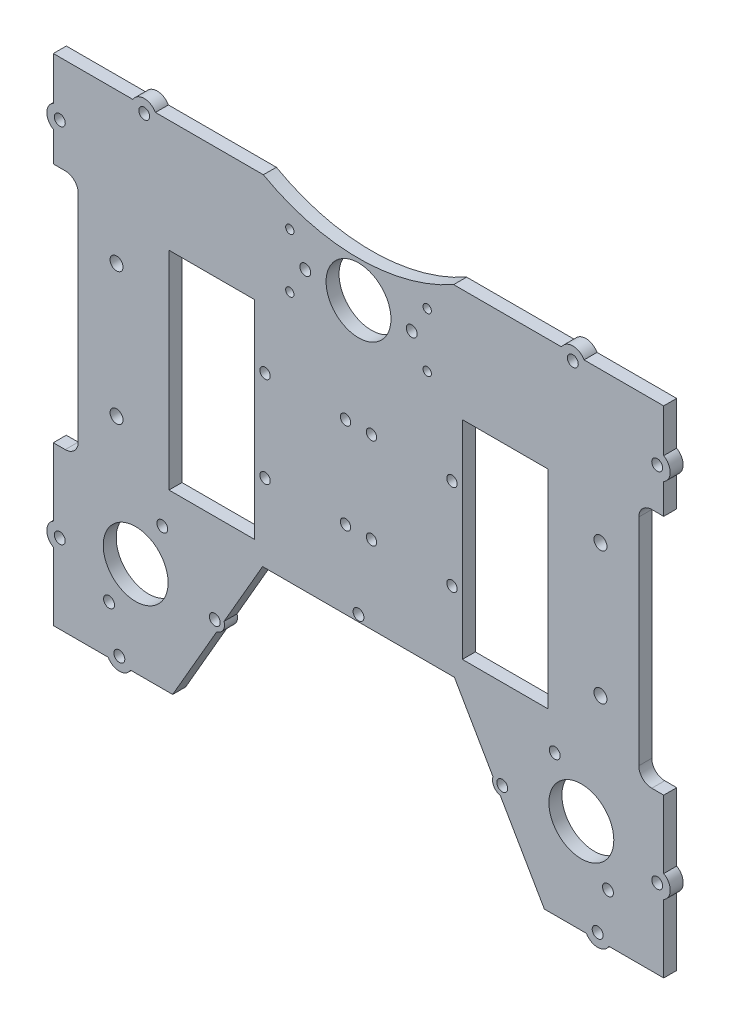
from build123d import *

# Parameters (mm, degrees)
BOSS_EXTRUDE1_DEPTH  = 5
CUT_EXTRUDE1_DEPTH   = 5
FILLET1_R            = 10
BOSS_EXTRUDE2_DEPTH  = 5
CUT_EXTRUDE3_DEPTH   = 10
SKETCH8_R            = 12.5
SKETCH8_R_2          = 2.1
CUT_EXTRUDE4_DEPTH   = 10
CUT_EXTRUDE5_DEPTH   = 10
FILLET4_R            = 10
CUT_EXTRUDE6_DEPTH   = 55
SKETCH12_R           = 12.5
SKETCH12_R_2         = 2.1
CUT_EXTRUDE7_DEPTH   = 10
SKETCH13_R           = 2.1
SKETCH13_R_2         = 2.097880452
CUT_EXTRUDE8_DEPTH   = 10
BOSS_EXTRUDE3_DEPTH  = 5
SKETCH15_R           = 1.6
CUT_EXTRUDE9_DEPTH   = 10
CUT_EXTRUDE10_DEPTH  = 10
FILLET5_R            = 15
SKETCH17_R           = 2.1
SKETCH17_R_2         = 12.5
BOSS_EXTRUDE4_DEPTH  = 5
CUT_EXTRUDE11_DEPTH  = 5
CUT_EXTRUDE13_DEPTH  = 5
BOSS_EXTRUDE7_DEPTH  = 5
SKETCH25_R           = 2.1
CUT_EXTRUDE15_DEPTH  = 5
BOSS_EXTRUDE8_DEPTH  = 5
SKETCH29_R           = 12.5
SKETCH29_R_2         = 2.1
CUT_EXTRUDE17_DEPTH  = 5
SKETCH31_R           = 2.1
SKETCH31_R_2         = 12.5
BOSS_EXTRUDE10_DEPTH = 5
SKETCH32_R           = 2.1
BOSS_EXTRUDE11_DEPTH = 5
SKETCH33_R           = 2.1
BOSS_EXTRUDE12_DEPTH = 5
CUT_EXTRUDE19_DEPTH  = 5
SKETCH37_W           = 236.187739262
SKETCH37_H           = 47.633249939
CUT_EXTRUDE21_DEPTH  = 10
CUT_EXTRUDE22_DEPTH  = 10
SKETCH41_R           = 12.5
SKETCH41_R_2         = 2.1
CUT_EXTRUDE23_DEPTH  = 10
SKETCH43_R           = 2
SKETCH43_W           = 33
SKETCH43_H           = 80
CUT_EXTRUDE24_DEPTH  = 10
SKETCH44_R           = 2.5
CUT_EXTRUDE25_DEPTH  = 10
SKETCH45_W           = 13.3
SKETCH45_H           = 92.98564038
CUT_EXTRUDE26_DEPTH  = 10
FILLET6_R            = 5
BOSS_EXTRUDE14_DEPTH = 5
SKETCH47_R           = 2.100093489
SKETCH47_R_2         = 2.1
SKETCH47_R_3         = 2.100705047
CUT_EXTRUDE27_DEPTH  = 5
SKETCH48_R           = 2.100208614
CUT_EXTRUDE28_DEPTH  = 5
CUT_EXTRUDE29_DEPTH  = 5
SKETCH50_R           = 2.100093489
SKETCH50_R_2         = 2.1
BOSS_EXTRUDE15_DEPTH = 5
BOSS_EXTRUDE16_DEPTH = 5
SKETCH53_R           = 2.1
CUT_EXTRUDE30_DEPTH  = 5


with BuildPart() as part:
    # Sketch2 → Boss-Extrude1 (new body)
    with BuildSketch(Plane.XY):
        with BuildLine():
            Line((118.854892482, -90.264830315), (131.354892482, -68.61419522))
            Line((131.354892482, -68.61419522), (131.354892482, -34.068551278))
            Line((131.354892482, -34.068551278), (131.354892482, -23.159839163))
            Line((131.354892482, -23.159839163), (131.354892482, 57.175005252))
            Line((131.354892482, 57.175005252), (131.354892482, 68.083717367))
            Line((131.354892482, 68.083717367), (131.354892482, 77.62936131))
            ThreePointArc((131.354892482, 77.62936131), (128.005527577, 90.12936131), (118.854892482, 99.279996404))
            Line((118.854892482, 99.279996404), (102.575593587, 108.678854004))
            Line((102.575593587, 108.678854004), (93.128371773, 114.133210061))
            Line((93.128371773, 114.133210061), (71.161779834, 126.81562783))
            ThreePointArc((71.161779834, 126.81562783), (70.530687733, 127.123084585), (69.862755205, 127.33912401))
            ThreePointArc((69.862755205, 127.33912401), (1.354892482, 71.71524119), (-67.152970241, 127.33912401))
            ThreePointArc((-67.152970241, 127.33912401), (-67.820902769, 127.123084585), (-68.45199487, 126.81562783))
            Line((-68.45199487, 126.81562783), (-90.418586809, 114.133210061))
            Line((-90.418586809, 114.133210061), (-99.865808623, 108.678854004))
            Line((-99.865808623, 108.678854004), (-116.145107518, 99.279996404))
            ThreePointArc((-116.145107518, 99.279996404), (-125.295742613, 90.12936131), (-128.645107518, 77.62936131))
            Line((-128.645107518, 77.62936131), (-128.645107518, 68.083717367))
            Line((-128.645107518, 68.083717367), (-128.645107518, 57.175005252))
            Line((-128.645107518, 57.175005252), (-128.645107518, -23.159839163))
            Line((-128.645107518, -23.159839163), (-128.645107518, -34.068551278))
            Line((-128.645107518, -34.068551278), (-128.645107518, -68.61419522))
            Line((-128.645107518, -68.61419522), (-116.145107518, -90.264830315))
            Line((-116.145107518, -90.264830315), (-48.645107518, -129.235973485))
            Line((-48.645107518, -129.235973485), (51.354892482, -129.235973485))
            Line((51.354892482, -129.235973485), (118.854892482, -90.264830315))
        make_face()
    extrude(amount=BOSS_EXTRUDE1_DEPTH)

    # Sketch4 → Cut-Extrude1 (cut)
    with BuildSketch(Plane.XY.offset(5)):
        with BuildLine():
            Line((76.324939807, 123.83467603), (71.161779834, 126.81562783))
            ThreePointArc((71.161779834, 126.81562783), (70.530687733, 127.123084585), (69.862755205, 127.33912401))
            ThreePointArc((69.862755205, 127.33912401), (1.354892482, 71.71524119), (-67.152970241, 127.33912401))
            ThreePointArc((-67.152970241, 127.33912401), (-67.820902769, 127.123084585), (-68.45199487, 126.81562783))
            Line((-68.45199487, 126.81562783), (-73.615154843, 123.83467603))
            ThreePointArc((-73.615154843, 123.83467603), (1.354892482, 46.71524119), (76.324939807, 123.83467603))
        make_face()
    extrude(amount=-CUT_EXTRUDE1_DEPTH, mode=Mode.SUBTRACT)

    # Fillet1
    fillet1_edges = [part.edges().sort_by_distance(p)[0] for p in [
        (76.324939807, 123.83467603, 2.5),
        (-73.615154843, 123.83467603, 2.5),
    ]]
    fillet(fillet1_edges, radius=FILLET1_R)

    # Sketch6 → Boss-Extrude2 (add)
    with BuildSketch(Plane.XY.offset(5)):
        Polygon((-128.645107518, -68.61419522), (-128.645107518, -169.952052331), (131.354892482, -169.952052331), (131.354892482, -68.61419522), (118.854892482, -90.264830315), (51.354892482, -129.235973485), (-48.645107518, -129.235973485), (-116.145107518, -90.264830315), align=None)
    extrude(amount=-BOSS_EXTRUDE2_DEPTH)

    # Sketch7 → Cut-Extrude3 (cut)
    with BuildSketch(Plane.XY.offset(5)):
        with BuildLine():
            Line((-116.215107518, -61.28475881), (-116.213411879, 18.71524119))
            Line((-116.213411879, 18.71524119), (-116.145107518, 99.279996404))
            ThreePointArc((-116.145107518, 99.279996404), (-125.295742613, 90.12936131), (-128.645107518, 77.62936131))
            Line((-128.645107518, 77.62936131), (-128.645107518, -169.952052331))
            Line((-128.645107518, -169.952052331), (-116.215107518, -169.952052331))
            Line((-116.215107518, -169.952052331), (-116.215107518, -61.28475881))
        make_face()
        with BuildLine():
            Line((118.924892482, -61.28475881), (118.924892482, -169.952052331))
            Line((118.924892482, -169.952052331), (131.354892482, -169.952052331))
            Line((131.354892482, -169.952052331), (131.354892482, 77.62936131))
            ThreePointArc((131.354892482, 77.62936131), (128.005527577, 90.12936131), (118.854892482, 99.279996404))
            Line((118.854892482, 99.279996404), (118.923196843, 18.71524119))
            Line((118.923196843, 18.71524119), (118.924892482, -61.28475881))
        make_face()
    extrude(amount=-CUT_EXTRUDE3_DEPTH, mode=Mode.SUBTRACT)

    # Sketch8 → Cut-Extrude4 (cut)
    with BuildSketch(Plane.XY.offset(5)):
        with Locations((1.354892482, -101.28475881)):
            Circle(SKETCH8_R)
        with Locations((21.854892482, -101.28475881)):
            Circle(SKETCH8_R_2)
        with Locations((-19.145107518, -101.28475881)):
            Circle(SKETCH8_R_2)
    extrude(amount=-CUT_EXTRUDE4_DEPTH, mode=Mode.SUBTRACT)

    # Sketch9 → Cut-Extrude5 (cut)
    with BuildSketch(Plane.XY.offset(5)):
        Polygon((118.924892482, -109.218146566), (94.040227372, -122.072981182), (-85.038192982, -122.072981182), (-116.215107518, -102.072981182), (-116.215107518, -169.952052331), (118.924892482, -169.952052331), align=None)
    extrude(amount=-CUT_EXTRUDE5_DEPTH, mode=Mode.SUBTRACT)

    # Fillet4
    fillet4_edges = [part.edges().sort_by_distance(p)[0] for p in [
        (-116.145107518, 99.279996404, 2.5),
        (118.854892482, 99.279996404, 2.5),
    ]]
    fillet(fillet4_edges, radius=FILLET4_R)

    # Sketch11 → Cut-Extrude6 (cut)
    with BuildSketch(Plane.XY.offset(5)):
        Polygon((115.38261843, -104.345351046), (87.747977946, -122.072981182), (94.040227372, -122.072981182), (118.924892482, -109.218146566), (118.924892482, -102.072981182), align=None)
    extrude(amount=-CUT_EXTRUDE6_DEPTH, mode=Mode.SUBTRACT)

    # Sketch12 → Cut-Extrude7 (cut)
    with BuildSketch(Plane.XY.offset(5)):
        with Locations((-87.399361691, 75.876360496)):
            Circle(SKETCH12_R)
        with Locations((-87.399361691, 96.376360496)):
            Circle(SKETCH12_R_2)
        with Locations((-87.399361691, 55.376360496)):
            Circle(SKETCH12_R_2)
        with Locations((90.109146655, 55.376360496)):
            Circle(SKETCH12_R_2)
        with Locations((90.109146655, 75.876360496)):
            Circle(SKETCH12_R)
        with Locations((90.109146655, 96.376360496)):
            Circle(SKETCH12_R_2)
    extrude(amount=-CUT_EXTRUDE7_DEPTH, mode=Mode.SUBTRACT)

    # Sketch13 → Cut-Extrude8 (cut)
    with BuildSketch(Plane.XY.offset(5)):
        with Locations((-97.505640106, -111.104922173)):
            Circle(SKETCH13_R)
        with Locations((-40.491777132, -119.572981182)):
            Circle(SKETCH13_R)
        with Locations((-113.715107518, -81.678869996)):
            Circle(SKETCH13_R)
        with Locations((-113.681704746, 56.11369386)):
            Circle(SKETCH13_R_2)
        with Locations((116.39148971, 56.11369386)):
            Circle(SKETCH13_R_2)
        with Locations((116.424892482, -81.678869996)):
            Circle(SKETCH13_R)
        with Locations((43.201562096, -119.572981182)):
            Circle(SKETCH13_R)
        with Locations((100.21542507, -111.104922173)):
            Circle(SKETCH13_R)
    extrude(amount=-CUT_EXTRUDE8_DEPTH, mode=Mode.SUBTRACT)

    # Sketch14 → Boss-Extrude3 (add)
    with BuildSketch(Plane.XY.offset(5)):
        with BuildLine():
            Line((-95.210855805, -115.547214938), (-102.500170642, -110.87111729))
            ThreePointArc((-102.500170642, -110.87111729), (-100.205386341, -115.313410056), (-95.210855805, -115.547214938))
        make_face()
        with BuildLine():
            Line((-116.215107518, -77.348742977), (-116.215107518, -86.008997015))
            ThreePointArc((-116.215107518, -86.008997015), (-118.715107518, -81.678869996), (-116.215107518, -77.348742977))
        make_face()
        with BuildLine():
            Line((-116.185374114, 51.785687426), (-116.178031784, 60.445939388))
            ThreePointArc((-116.178031784, 60.445939388), (-118.681702949, 56.117932955), (-116.185374114, 51.785687426))
        make_face()
        with BuildLine():
            Line((-36.161650113, -122.072981182), (-44.821904151, -122.072981182))
            ThreePointArc((-44.821904151, -122.072981182), (-40.491777132, -124.572981182), (-36.161650113, -122.072981182))
        make_face()
        with BuildLine():
            Line((38.871435077, -122.072981182), (47.531689115, -122.072981182))
            ThreePointArc((47.531689115, -122.072981182), (43.201562096, -124.572981182), (38.871435077, -122.072981182))
        make_face()
        with BuildLine():
            Line((118.895159078, 51.785687426), (118.887816748, 60.445939388))
            ThreePointArc((118.887816748, 60.445939388), (121.391487913, 56.117932955), (118.895159078, 51.785687426))
        make_face()
        with BuildLine():
            Line((118.924892482, -77.348742977), (118.924892482, -86.008997015))
            ThreePointArc((118.924892482, -86.008997015), (121.424892482, -81.678869996), (118.924892482, -77.348742977))
        make_face()
        with BuildLine():
            Line((97.920640769, -115.547214938), (105.209955606, -110.87111729))
            ThreePointArc((105.209955606, -110.87111729), (102.915171306, -115.313410056), (97.920640769, -115.547214938))
        make_face()
    extrude(amount=-BOSS_EXTRUDE3_DEPTH)

    # Sketch15 → Cut-Extrude9 (cut)
    with BuildSketch(Plane.XY.offset(5)):
        with Locations((-25.109573612, 25.679707284)):
            Circle(SKETCH15_R)
        with Locations((-25.109573612, 4.750775096)):
            Circle(SKETCH15_R)
        with Locations((27.819358576, 25.679707284)):
            Circle(SKETCH15_R)
        with Locations((27.819358576, 4.750775096)):
            Circle(SKETCH15_R)
    extrude(amount=-CUT_EXTRUDE9_DEPTH, mode=Mode.SUBTRACT)

    # Sketch16 → Cut-Extrude10 (cut)
    with BuildSketch(Plane.XY.offset(5)):
        with BuildLine():
            ThreePointArc((-72.545920023, 108.921887014), (1.354892482, 46.71524119), (75.255704987, 108.921887014))
            ThreePointArc((75.255704987, 108.921887014), (75.555506148, 110.170417386), (76.012819022, 111.370239773))
            ThreePointArc((76.012819022, 111.370239773), (1.354892482, 29.21524119), (-73.303034058, 111.370239773))
            ThreePointArc((-73.303034058, 111.370239773), (-72.845721184, 110.170417386), (-72.545920023, 108.921887014))
        make_face()
    extrude(amount=-CUT_EXTRUDE10_DEPTH, mode=Mode.SUBTRACT)

    # Fillet5
    fillet5_edges = [part.edges().sort_by_distance(p)[0] for p in [
        (76.012819022, 111.370239773, 2.5),
        (-73.303034058, 111.370239773, 2.5),
    ]]
    fillet(fillet5_edges, radius=FILLET5_R)

    # Sketch17 → Boss-Extrude4 (add)
    with BuildSketch(Plane.XY.offset(5)):
        with Locations((90.109146655, 55.376360496)):
            Circle(SKETCH17_R)
        with Locations((90.109146655, 96.376360496)):
            Circle(SKETCH17_R)
        with Locations((90.109146655, 75.876360496)):
            Circle(SKETCH17_R_2)
        with Locations((-87.399361691, 55.376360496)):
            Circle(SKETCH17_R)
        with Locations((-87.399361691, 96.376360496)):
            Circle(SKETCH17_R)
        with Locations((-87.399361691, 75.876360496)):
            Circle(SKETCH17_R_2)
    extrude(amount=-BOSS_EXTRUDE4_DEPTH)

    # Sketch18 → Cut-Extrude11 (cut)
    with BuildSketch(Plane.XY.offset(5)):
        with BuildLine():
            Line((-116.179388511, 58.845685421), (-71.106807034, 84.868352469))
            ThreePointArc((-71.106807034, 84.868352469), (-72.623753721, 91.879929846), (-73.463866886, 99.004363469))
            ThreePointArc((-73.463866886, 99.004363469), (-81.383699272, 111.205420092), (-95.92761876, 110.952568981))
            Line((-95.92761876, 110.952568981), (-111.150001207, 102.163922378))
            ThreePointArc((-111.150001207, 102.163922378), (-114.808134919, 98.507339055), (-116.149997613, 93.51214653))
            Line((-116.149997613, 93.51214653), (-116.178031784, 60.445939388))
            Line((-116.178031784, 60.445939388), (-116.179388511, 58.845685421))
        make_face()
        with BuildLine():
            Line((118.887816748, 60.445939388), (118.889173475, 58.845685421))
            Line((118.889173475, 58.845685421), (73.816591999, 84.868352469))
            ThreePointArc((73.816591999, 84.868352469), (75.333538685, 91.879929846), (76.17365185, 99.004363469))
            ThreePointArc((76.17365185, 99.004363469), (84.093484236, 111.205420092), (98.637403724, 110.952568981))
            Line((98.637403724, 110.952568981), (113.859786171, 102.163922378))
            ThreePointArc((113.859786171, 102.163922378), (117.517919883, 98.507339055), (118.859782577, 93.51214653))
            Line((118.859782577, 93.51214653), (118.887816748, 60.445939388))
        make_face()
    extrude(amount=-CUT_EXTRUDE11_DEPTH, mode=Mode.SUBTRACT)

    # Sketch20 → Cut-Extrude13 (cut)
    with BuildSketch(Plane.XY.offset(5)):
        with BuildLine():
            Line((-116.185374114, 51.785687426), (-116.179388511, 58.845685421))
            Line((-116.179388511, 58.845685421), (-116.178031784, 60.445939388))
            ThreePointArc((-116.178031784, 60.445939388), (-118.681702949, 56.117932955), (-116.185374114, 51.785687426))
        make_face()
        with BuildLine():
            Line((118.889173475, 58.845685421), (118.887816748, 60.445939388))
            ThreePointArc((118.887816748, 60.445939388), (121.391487913, 56.117932955), (118.895159078, 51.785687426))
            Line((118.895159078, 51.785687426), (118.889173475, 58.845685421))
        make_face()
    extrude(amount=-CUT_EXTRUDE13_DEPTH, mode=Mode.SUBTRACT)

    # Sketch24 → Boss-Extrude7 (add)
    with BuildSketch(Plane.XY.offset(5)):
        with BuildLine():
            Line((118.909854527, 34.452456871), (118.902512197, 43.112708833))
            ThreePointArc((118.902512197, 43.112708833), (121.406183362, 38.7847024), (118.909854527, 34.452456871))
        make_face()
        with BuildLine():
            Line((-116.200069563, 34.452456871), (-116.192727233, 43.112708833))
            ThreePointArc((-116.192727233, 43.112708833), (-118.696398398, 38.7847024), (-116.200069563, 34.452456871))
        make_face()
    extrude(amount=-BOSS_EXTRUDE7_DEPTH)

    # Sketch25 → Cut-Extrude15 (cut)
    with BuildSketch(Plane.XY.offset(5)):
        with Locations((-113.696400195, 38.780463305)):
            Circle(SKETCH25_R)
        with Locations((116.406185159, 38.780463305)):
            Circle(SKETCH25_R)
    extrude(amount=-CUT_EXTRUDE15_DEPTH, mode=Mode.SUBTRACT)

    # Sketch26 → Boss-Extrude8 (add)
    with BuildSketch(Plane.XY.offset(5)):
        with BuildLine():
            Line((-56.145107518, -152.072981182), (-26.145107518, -122.072981182))
            Line((-26.145107518, -122.072981182), (-36.161650113, -122.072981182))
            ThreePointArc((-36.161650113, -122.072981182), (-40.491777132, -124.572981182), (-44.821904151, -122.072981182))
            Line((-44.821904151, -122.072981182), (-85.038192982, -122.072981182))
            Line((-85.038192982, -122.072981182), (-95.210855805, -115.547214938))
            ThreePointArc((-95.210855805, -115.547214938), (-100.205386341, -115.313410056), (-102.500170642, -110.87111729))
            Line((-102.500170642, -110.87111729), (-116.215107518, -102.072981182))
            Line((-116.215107518, -102.072981182), (-116.215107518, -152.072981182))
            Line((-116.215107518, -152.072981182), (-105.295228274, -152.072981182))
            Line((-105.295228274, -152.072981182), (-56.145107518, -152.072981182))
        make_face()
        with BuildLine():
            ThreePointArc((97.920640769, -115.547214938), (102.915171306, -115.313410056), (105.209955606, -110.87111729))
            Line((105.209955606, -110.87111729), (118.924892482, -102.072981182))
            Line((118.924892482, -102.072981182), (118.924892482, -152.072981182))
            Line((118.924892482, -152.072981182), (108.005013238, -152.072981182))
            Line((108.005013238, -152.072981182), (58.854892482, -152.072981182))
            Line((58.854892482, -152.072981182), (28.854892482, -122.072981182))
            Line((28.854892482, -122.072981182), (38.871435077, -122.072981182))
            ThreePointArc((38.871435077, -122.072981182), (43.201562096, -124.572981182), (47.531689115, -122.072981182))
            Line((47.531689115, -122.072981182), (87.747977946, -122.072981182))
            Line((87.747977946, -122.072981182), (97.920640769, -115.547214938))
        make_face()
    extrude(amount=-BOSS_EXTRUDE8_DEPTH)

    # Sketch29 → Cut-Extrude17 (cut)
    with BuildSketch(Plane.XY.offset(5)):
        with Locations((1.354892482, 15.21524119)):
            Circle(SKETCH29_R)
        with Locations((21.854892482, 15.21524119)):
            Circle(SKETCH29_R_2)
        with Locations((-19.145107518, 15.21524119)):
            Circle(SKETCH29_R_2)
    extrude(amount=-CUT_EXTRUDE17_DEPTH, mode=Mode.SUBTRACT)

    # Sketch31 → Boss-Extrude10 (add)
    with BuildSketch(Plane.XY.offset(5)):
        with Locations((-19.145107518, -101.28475881)):
            Circle(SKETCH31_R)
        with Locations((21.854892482, -101.28475881)):
            Circle(SKETCH31_R)
        with Locations((1.354892482, -101.28475881)):
            Circle(SKETCH31_R_2)
    extrude(amount=-BOSS_EXTRUDE10_DEPTH)

    # Sketch32 → Boss-Extrude11 (add)
    with BuildSketch(Plane.XY.offset(5)):
        with Locations((100.21542507, -111.104922173)):
            Circle(SKETCH32_R)
        with Locations((43.201562096, -119.572981182)):
            Circle(SKETCH32_R)
        with Locations((-97.505640106, -111.104922173)):
            Circle(SKETCH32_R)
        with Locations((-40.491777132, -119.572981182)):
            Circle(SKETCH32_R)
    extrude(amount=-BOSS_EXTRUDE11_DEPTH)

    # Sketch33 → Boss-Extrude12 (add)
    with BuildSketch(Plane.XY.offset(5)):
        with Locations((116.406185159, 38.780463305)):
            Circle(SKETCH33_R)
        with Locations((116.424892482, -81.678869996)):
            Circle(SKETCH33_R)
        with Locations((-113.715107518, -81.678869996)):
            Circle(SKETCH33_R)
        with Locations((-113.696400195, 38.780463305)):
            Circle(SKETCH33_R)
    extrude(amount=-BOSS_EXTRUDE12_DEPTH)

    # Sketch34 → Cut-Extrude19 (cut)
    with BuildSketch(Plane.XY.offset(5)):
        with BuildLine():
            Line((-116.192727233, 43.112708833), (-116.200069563, 34.452456871))
            ThreePointArc((-116.200069563, 34.452456871), (-118.696398398, 38.7847024), (-116.192727233, 43.112708833))
        make_face()
        with BuildLine():
            Line((-116.215107518, -86.008997015), (-116.215107518, -77.348742977))
            ThreePointArc((-116.215107518, -77.348742977), (-118.715107518, -81.678869996), (-116.215107518, -86.008997015))
        make_face()
        with BuildLine():
            Line((118.902512197, 43.112708833), (118.909854527, 34.452456871))
            ThreePointArc((118.909854527, 34.452456871), (121.406183362, 38.7847024), (118.902512197, 43.112708833))
        make_face()
        with BuildLine():
            Line((118.924892482, -77.348742977), (118.924892482, -86.008997015))
            ThreePointArc((118.924892482, -86.008997015), (121.424892482, -81.678869996), (118.924892482, -77.348742977))
        make_face()
    extrude(amount=-CUT_EXTRUDE19_DEPTH, mode=Mode.SUBTRACT)

    # Sketch37 → Cut-Extrude21 (cut)
    with BuildSketch(Plane.XY.offset(5)):
        with Locations((1.897469436, 62.597088275)):
            Rectangle(SKETCH37_W, SKETCH37_H)
    extrude(amount=-CUT_EXTRUDE21_DEPTH, mode=Mode.SUBTRACT)

    # Sketch38 → Cut-Extrude22 (cut)
    with BuildSketch(Plane.XY.offset(5)):
        Polygon((-35.595524746, -92.072981182), (33.754047831, -92.072981182), (38.30530971, -92.072981182), (72.946325862, -152.072981182), (58.854892482, -152.072981182), (28.854892482, -122.072981182), (-26.145107518, -122.072981182), (-56.145107518, -152.072981182), (-70.236540897, -152.072981182), align=None)
    extrude(amount=-CUT_EXTRUDE22_DEPTH, mode=Mode.SUBTRACT)

    # Sketch41 → Cut-Extrude23 (cut)
    with BuildSketch(Plane.XY.offset(5)):
        with Locations((87.197008489, -115.686016305)):
            Circle(SKETCH41_R)
        with Locations((97.447008489, -133.439537083)):
            Circle(SKETCH41_R_2)
        with Locations((76.947008489, -97.932495528)):
            Circle(SKETCH41_R_2)
        with Locations((-74.237223525, -97.932495528)):
            Circle(SKETCH41_R_2)
        with Locations((-94.737223525, -133.439537083)):
            Circle(SKETCH41_R_2)
        with Locations((-84.487223525, -115.686016305)):
            Circle(SKETCH41_R)
    extrude(amount=-CUT_EXTRUDE23_DEPTH, mode=Mode.SUBTRACT)

    # Sketch43 → Cut-Extrude24 (cut)
    with BuildSketch(Plane.XY.offset(5)):
        with Locations((-34.645107518, -27.072981182)):
            Circle(SKETCH43_R)
        with Locations((-3.645107518, -27.072981182)):
            Circle(SKETCH43_R)
        with Locations((6.354892482, -27.072981182)):
            Circle(SKETCH43_R)
        with Locations((37.354892482, -27.072981182)):
            Circle(SKETCH43_R)
        with Locations((-34.645107518, -62.072981182)):
            Circle(SKETCH43_R)
        with Locations((-3.645107518, -62.072981182)):
            Circle(SKETCH43_R)
        with Locations((6.354892482, -62.072981182)):
            Circle(SKETCH43_R)
        with Locations((37.354892482, -62.072981182)):
            Circle(SKETCH43_R)
        with Locations((-55.145107518, -44.572981182)):
            Rectangle(SKETCH43_W, SKETCH43_H)
        with Locations((57.854892482, -44.572981182)):
            Rectangle(SKETCH43_W, SKETCH43_H)
    extrude(amount=-CUT_EXTRUDE24_DEPTH, mode=Mode.SUBTRACT)

    # Sketch44 → Cut-Extrude25 (cut)
    with BuildSketch(Plane.XY.offset(5)):
        with Locations((-91.845107518, -19.072981182)):
            Circle(SKETCH44_R)
        with Locations((-91.845107518, -70.072981182)):
            Circle(SKETCH44_R)
        with Locations((94.554892482, -19.072981182)):
            Circle(SKETCH44_R)
        with Locations((94.554892482, -70.072981182)):
            Circle(SKETCH44_R)
    extrude(amount=-CUT_EXTRUDE25_DEPTH, mode=Mode.SUBTRACT)

    # Sketch45 → Cut-Extrude26 (cut)
    with BuildSketch(Plane.XY.offset(5)):
        with Locations((-113.265107518, -44.572981182)):
            Rectangle(SKETCH45_W, SKETCH45_H)
        with Locations((115.974892482, -44.572981182)):
            Rectangle(SKETCH45_W, SKETCH45_H)
    extrude(amount=-CUT_EXTRUDE26_DEPTH, mode=Mode.SUBTRACT)

    # Fillet6
    fillet6_edges = [part.edges().sort_by_distance(p)[0] for p in [
        (-106.615107518, 1.919839008, 2.5),
        (-106.615107518, -91.065801372, 2.5),
        (109.324892482, -91.065801372, 2.5),
        (109.324892482, 1.919839008, 2.5),
    ]]
    fillet(fillet6_edges, radius=FILLET6_R)

    # Sketch46 → Boss-Extrude14 (add)
    with BuildSketch(Plane.XY.offset(5)):
        with BuildLine():
            Line((-116.213411879, 18.71524119), (-116.210476707, 22.177266344))
            ThreePointArc((-116.210476707, 22.177266344), (-118.704727915, 17.852223146), (-116.21352188, 13.525425225))
            Line((-116.21352188, 13.525425225), (-116.213411879, 18.71524119))
        make_face()
        with BuildLine():
            Line((-80.076246748, 38.780463305), (-71.41599271, 38.780463305))
            ThreePointArc((-71.41599271, 38.780463305), (-75.746119729, 41.280463305), (-80.076246748, 38.780463305))
        make_face()
        with BuildLine():
            Line((-116.215107518, -117.237854163), (-116.215107518, -125.898108201))
            ThreePointArc((-116.215107518, -125.898108201), (-118.715107518, -121.567981182), (-116.215107518, -117.237854163))
        make_face()
        with BuildLine():
            Line((55.951852196, -122.637689346), (53.156767224, -117.796460163))
            ThreePointArc((53.156767224, -117.796460163), (53.471777955, -120.842074754), (55.951852196, -122.637689346))
        make_face()
        with BuildLine():
            Line((97.810019501, -152.072981182), (89.149765463, -152.072981182))
            ThreePointArc((89.149765463, -152.072981182), (93.479892482, -154.572981182), (97.810019501, -152.072981182))
        make_face()
        with BuildLine():
            Line((118.924892482, -117.238559211), (118.924892482, -125.898813249))
            ThreePointArc((118.924892482, -125.898813249), (121.424892482, -121.56868623), (118.924892482, -117.238559211))
        make_face()
        with BuildLine():
            Line((118.923196843, 18.71524119), (118.923306737, 13.530484573))
            ThreePointArc((118.923306737, 13.530484573), (121.405810895, 17.852222664), (118.920265956, 22.172212639))
            Line((118.920265956, 22.172212639), (118.923196843, 18.71524119))
        make_face()
        with BuildLine():
            Line((74.125684186, 38.780463305), (82.785938223, 38.780463305))
            ThreePointArc((82.785938223, 38.780463305), (78.455811205, 41.280463305), (74.125684186, 38.780463305))
        make_face()
        with BuildLine():
            ThreePointArc((-95.100234537, -152.072981182), (-90.770107518, -154.572981182), (-86.439980499, -152.072981182))
            Line((-86.439980499, -152.072981182), (-95.100234537, -152.072981182))
        make_face()
        with BuildLine():
            ThreePointArc((-53.242067232, -122.637689346), (-50.761992991, -120.842074754), (-50.44698226, -117.796460163))
            Line((-50.44698226, -117.796460163), (-53.242067232, -122.637689346))
        make_face()
    extrude(amount=-BOSS_EXTRUDE14_DEPTH)

    # Sketch47 → Cut-Extrude27 (cut)
    with BuildSketch(Plane.XY.offset(5)):
        with Locations((-75.746119729, 36.280463305)):
            Circle(SKETCH47_R)
        with Locations((-113.715107518, -121.567981182)):
            Circle(SKETCH47_R_2)
        with Locations((-90.770107518, -149.572981182)):
            Circle(SKETCH47_R_2)
        with Locations((-54.009588256, -118.967074754)):
            Circle(SKETCH47_R_2)
        with Locations((56.71937322, -118.967074754)):
            Circle(SKETCH47_R_2)
        with Locations((93.479892482, -149.572981182)):
            Circle(SKETCH47_R_2)
        with Locations((116.424892482, -121.56868623)):
            Circle(SKETCH47_R_3)
        with Locations((116.405811205, 17.850463305)):
            Circle(SKETCH47_R_2)
        with Locations((78.455811205, 36.280463305)):
            Circle(SKETCH47_R_2)
        with Locations((-113.704728224, 17.850463305)):
            Circle(SKETCH47_R_2)
    extrude(amount=-CUT_EXTRUDE27_DEPTH, mode=Mode.SUBTRACT)

    # Sketch48 → Cut-Extrude28 (cut)
    with BuildSketch(Plane.XY.offset(5)):
        with Locations((1.355101096, -89.572981182)):
            Circle(SKETCH48_R)
    extrude(amount=-CUT_EXTRUDE28_DEPTH, mode=Mode.SUBTRACT)

    # Sketch49 → Cut-Extrude29 (cut)
    with BuildSketch(Plane.XY.offset(5)):
        with BuildLine():
            Line((-80.076246748, 38.780463305), (-71.41599271, 38.780463305))
            ThreePointArc((-71.41599271, 38.780463305), (-75.746119729, 41.280463305), (-80.076246748, 38.780463305))
        make_face()
        with BuildLine():
            Line((74.125684186, 38.780463305), (82.785938223, 38.780463305))
            ThreePointArc((82.785938223, 38.780463305), (78.455811205, 41.280463305), (74.125684186, 38.780463305))
        make_face()
    extrude(amount=-CUT_EXTRUDE29_DEPTH, mode=Mode.SUBTRACT)

    # Sketch50 → Boss-Extrude15 (add)
    with BuildSketch(Plane.XY.offset(5)):
        with Locations((-75.746119729, 36.280463305)):
            Circle(SKETCH50_R)
        with Locations((78.455811205, 36.280463305)):
            Circle(SKETCH50_R_2)
    extrude(amount=-BOSS_EXTRUDE15_DEPTH)

    # Sketch52 → Boss-Extrude16 (add)
    with BuildSketch(Plane.XY.offset(5)):
        with BuildLine():
            Line((79.57605814, 38.780463305), (88.236312178, 38.780463305))
            ThreePointArc((88.236312178, 38.780463305), (83.906185159, 41.280463305), (79.57605814, 38.780463305))
        make_face()
        with BuildLine():
            Line((-76.866273176, 38.780463305), (-85.526527214, 38.780463305))
            ThreePointArc((-85.526527214, 38.780463305), (-81.196400195, 41.280463305), (-76.866273176, 38.780463305))
        make_face()
    extrude(amount=-BOSS_EXTRUDE16_DEPTH)

    # Sketch53 → Cut-Extrude30 (cut)
    with BuildSketch(Plane.XY.offset(5)):
        with Locations((83.906185159, 36.280463305)):
            Circle(SKETCH53_R)
        with Locations((-81.196400195, 36.280463305)):
            Circle(SKETCH53_R)
    extrude(amount=-CUT_EXTRUDE30_DEPTH, mode=Mode.SUBTRACT)


solid = part.part
